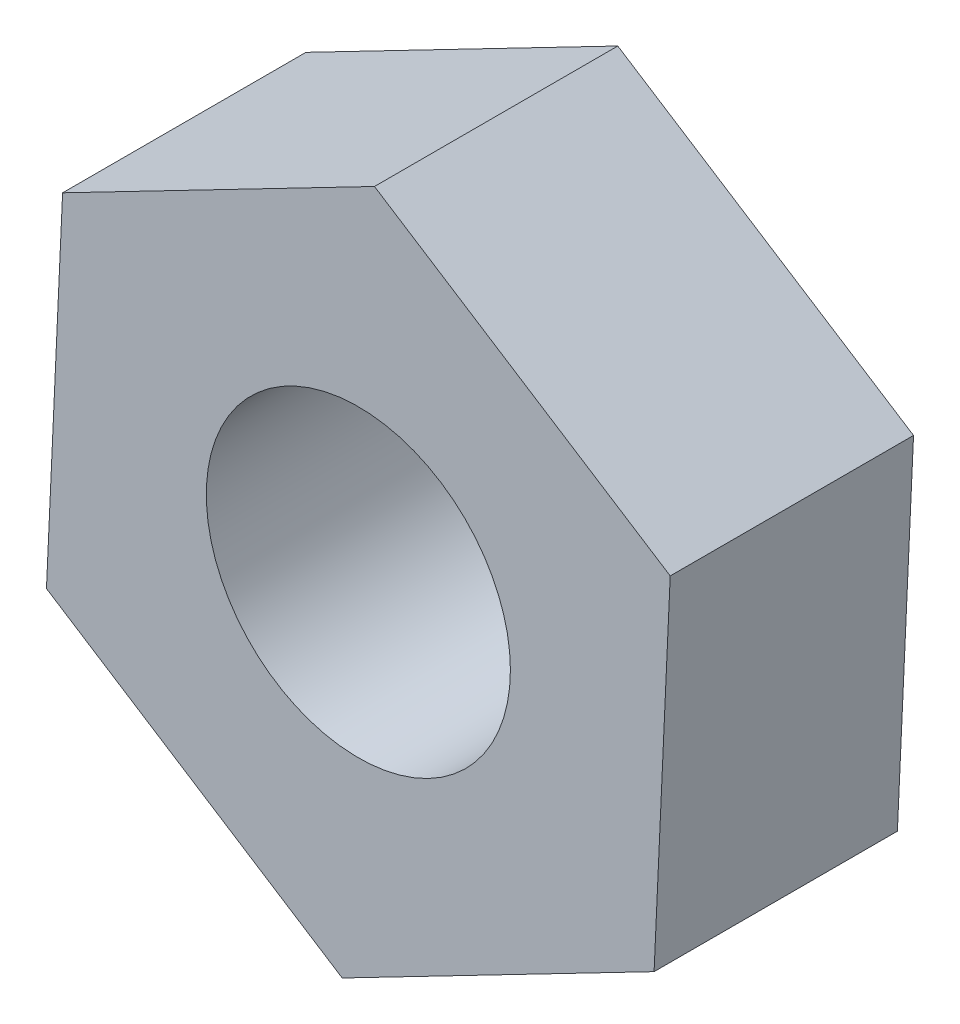
from build123d import *

# Parameters (mm, degrees)
SKETCH_1_R      = 1
EXTRUDE_1_DEPTH = 1.6


with BuildPart() as part:
    # ｽｹｯﾁ1 → ﾎﾞｽ - 押し出し1 (new body)
    with BuildSketch(Plane.XY):
        Polygon((-2.050945843, -1.061581123), (-0.106116701, -2.306961764), (1.944829142, -1.245380641), (2.050945843, 1.061581123), (0.106116701, 2.306961764), (-1.944829142, 1.245380641), align=None)
        Circle(SKETCH_1_R, mode=Mode.SUBTRACT)
    extrude(amount=EXTRUDE_1_DEPTH)


solid = part.part
